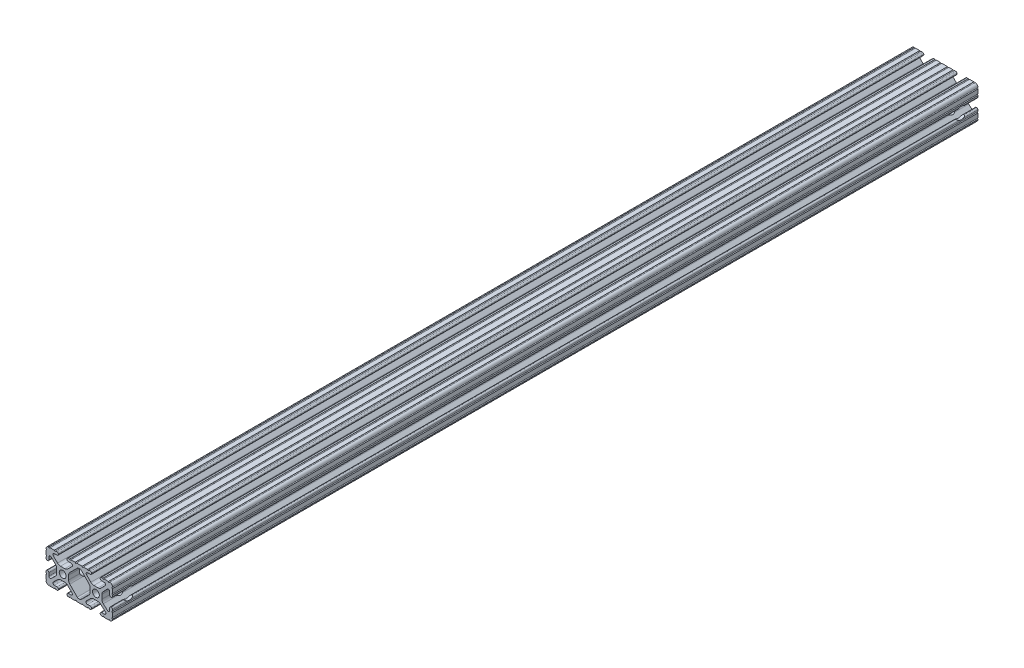
from build123d import *

# Parameters (mm, degrees)
SKETCH1_R               = 2.6035
BOSS_EXTRUDE1_DEPTH     = 330.2
SKETCH2_R               = 4.445
CUT_EXTRUDE1_DEPTH      = 9.191498123
CUT_EXTRUDE1_DEPTH_BACK = 43.608501877


with BuildPart() as part:
    # Sketch1 → Boss-Extrude1 (new body, symmetric)
    with BuildSketch(Plane.XY):
        with BuildLine():
            Line((18.01710265, 12.7), (16.98745015, 12.7))
            ThreePointArc((16.98745015, 12.7), (16.245730386, 12.392769614), (15.9385, 11.65104985))
            Line((15.9385, 11.65104985), (15.9385, 11.53922))
            ThreePointArc((15.9385, 11.53922), (16.245750844, 10.797450844), (16.98752, 10.4902))
            Line((16.98752, 10.4902), (19.116384363, 10.4902))
            ThreePointArc((19.116384363, 10.4902), (20.052502933, 9.869096983), (19.844087081, 8.765172272))
            Line((19.844087081, 8.765172272), (16.618993479, 5.455112286))
            ThreePointArc((16.618993479, 5.455112286), (15.578994274, 4.745442459), (14.344932584, 4.4958))
            Line((14.344932584, 4.4958), (11.083317835, 4.4958))
            ThreePointArc((11.083317835, 4.4958), (9.854330953, 4.743306833), (8.816955189, 5.447238587))
            Line((8.816955189, 5.447238587), (5.564154119, 8.762652677))
            ThreePointArc((5.564154119, 8.762652677), (5.352591412, 9.867473037), (6.289393385, 10.4902))
            Line((6.289393385, 10.4902), (8.41248, 10.4902))
            ThreePointArc((8.41248, 10.4902), (9.154249156, 10.797450844), (9.4615, 11.53922))
            Line((9.4615, 11.53922), (9.4615, 11.65104985))
            ThreePointArc((9.4615, 11.65104985), (9.154269614, 12.392769614), (8.41254985, 12.7))
            Line((8.41254985, 12.7), (7.38288465, 12.7))
            ThreePointArc((7.38288465, 12.7), (6.87488465, 12.192), (6.36688465, 12.7))
            Line((6.36688465, 12.7), (3.14958095, 12.7))
            ThreePointArc((3.14958095, 12.7), (2.64158095, 12.192), (2.13358095, 12.7))
            Line((2.13358095, 12.7), (-2.13358095, 12.7))
            ThreePointArc((-2.13358095, 12.7), (-2.64158095, 12.192), (-3.14958095, 12.7))
            Line((-3.14958095, 12.7), (-6.36689735, 12.7))
            ThreePointArc((-6.36689735, 12.7), (-6.87489735, 12.192), (-7.38289735, 12.7))
            Line((-7.38289735, 12.7), (-8.41254985, 12.7))
            ThreePointArc((-8.41254985, 12.7), (-9.154269614, 12.392769614), (-9.4615, 11.65104985))
            Line((-9.4615, 11.65104985), (-9.4615, 11.53922))
            ThreePointArc((-9.4615, 11.53922), (-9.154249156, 10.797450844), (-8.41248, 10.4902))
            Line((-8.41248, 10.4902), (-6.283641037, 10.4902))
            ThreePointArc((-6.283641037, 10.4902), (-5.297291557, 9.829633109), (-5.532576693, 8.666071843))
            Line((-5.532576693, 8.666071843), (-8.809985098, 5.416263103))
            ThreePointArc((-8.809985098, 5.416263103), (-9.836720513, 4.734920264), (-11.045536121, 4.4958))
            Line((-11.045536121, 4.4958), (-14.354463879, 4.4958))
            ThreePointArc((-14.354463879, 4.4958), (-15.563279487, 4.734920264), (-16.590014902, 5.416263103))
            Line((-16.590014902, 5.416263103), (-19.867423307, 8.666071843))
            ThreePointArc((-19.867423307, 8.666071843), (-20.102708443, 9.829633109), (-19.116358963, 10.4902))
            Line((-19.116358963, 10.4902), (-16.98752, 10.4902))
            ThreePointArc((-16.98752, 10.4902), (-16.245750844, 10.797450844), (-15.9385, 11.53922))
            Line((-15.9385, 11.53922), (-15.9385, 11.65104985))
            ThreePointArc((-15.9385, 11.65104985), (-16.245730386, 12.392769614), (-16.98745015, 12.7))
            Line((-16.98745015, 12.7), (-18.01711535, 12.7))
            ThreePointArc((-18.01711535, 12.7), (-18.52511535, 12.192), (-19.03311535, 12.7))
            Line((-19.03311535, 12.7), (-22.2504, 12.7))
            ThreePointArc((-22.2504, 12.7), (-22.758323491, 12.192000006), (-23.266399977, 12.699846982))
            ThreePointArc((-23.266399977, 12.699846982), (-24.782522516, 12.082522516), (-25.399846982, 10.566399977))
            ThreePointArc((-25.399846982, 10.566399977), (-24.892000006, 10.058323491), (-25.4, 9.5504))
            Line((-25.4, 9.5504), (-25.4, 6.3330836))
            ThreePointArc((-25.4, 6.3330836), (-24.892, 5.8250836), (-25.4, 5.3170836))
            Line((-25.4, 5.3170836), (-25.4, 4.237520184))
            ThreePointArc((-25.4, 4.237520184), (-25.107393763, 3.531106237), (-24.400979816, 3.2385))
            Line((-24.400979816, 3.2385), (-24.23922, 3.2385))
            ThreePointArc((-24.23922, 3.2385), (-23.497450844, 3.545750844), (-23.1902, 4.28752))
            Line((-23.1902, 4.28752), (-23.1902, 6.334741132))
            ThreePointArc((-23.1902, 6.334741132), (-22.556026952, 7.286023527), (-21.434002553, 7.066535717))
            Line((-21.434002553, 7.066535717), (-18.147950853, 3.808156468))
            ThreePointArc((-18.147950853, 3.808156468), (-17.452759693, 2.774838327), (-17.208501877, 1.553619571))
            Line((-17.208501877, 1.553619571), (-17.208501877, -1.695179196))
            ThreePointArc((-17.208501877, -1.695179196), (-17.450738657, -2.911536421), (-18.140486065, -3.942289578))
            Line((-18.140486065, -3.942289578), (-21.431579576, -7.227386226))
            ThreePointArc((-21.431579576, -7.227386226), (-22.55444896, -7.449940594), (-23.1902, -6.498002195))
            Line((-23.1902, -6.498002195), (-23.1902, -4.28752))
            ThreePointArc((-23.1902, -4.28752), (-23.497450844, -3.545750844), (-24.23922, -3.2385))
            Line((-24.23922, -3.2385), (-24.35098, -3.2385))
            ThreePointArc((-24.35098, -3.2385), (-25.092749156, -3.545750844), (-25.4, -4.28752))
            Line((-25.4, -4.28752), (-25.4, -5.3171344))
            ThreePointArc((-25.4, -5.3171344), (-24.892, -5.8251344), (-25.4, -6.3331344))
            Line((-25.4, -6.3331344), (-25.4, -9.5504))
            ThreePointArc((-25.4, -9.5504), (-24.892000006, -10.058323491), (-25.399846982, -10.566399977))
            ThreePointArc((-25.399846982, -10.566399977), (-24.782522516, -12.082522516), (-23.266399977, -12.699846982))
            ThreePointArc((-23.266399977, -12.699846982), (-22.758323491, -12.192000006), (-22.2504, -12.7))
            Line((-22.2504, -12.7), (-19.03308995, -12.7))
            ThreePointArc((-19.03308995, -12.7), (-18.52508995, -12.192), (-18.01708995, -12.7))
            Line((-18.01708995, -12.7), (-16.9874692, -12.7))
            ThreePointArc((-16.9874692, -12.7), (-16.245700044, -12.392749156), (-15.9384492, -11.65098))
            Line((-15.9384492, -11.65098), (-15.9384492, -11.53922))
            ThreePointArc((-15.9384492, -11.53922), (-16.245700044, -10.797450844), (-16.9874692, -10.4902))
            Line((-16.9874692, -10.4902), (-19.116358963, -10.4902))
            ThreePointArc((-19.116358963, -10.4902), (-20.055197748, -9.862578342), (-19.834124023, -8.755124678))
            Line((-19.834124023, -8.755124678), (-16.49660751, -5.423689618))
            ThreePointArc((-16.49660751, -5.423689618), (-15.467274017, -4.736928798), (-14.253591699, -4.4958))
            Line((-14.253591699, -4.4958), (-11.146408301, -4.4958))
            ThreePointArc((-11.146408301, -4.4958), (-9.932725983, -4.736928798), (-8.90339249, -5.423689618))
            Line((-8.90339249, -5.423689618), (-5.565875977, -8.755124678))
            ThreePointArc((-5.565875977, -8.755124678), (-5.344802252, -9.862578342), (-6.283641037, -10.4902))
            Line((-6.283641037, -10.4902), (-8.4125308, -10.4902))
            ThreePointArc((-8.4125308, -10.4902), (-9.154299956, -10.797450844), (-9.4615508, -11.53922))
            Line((-9.4615508, -11.53922), (-9.4615508, -11.65098))
            ThreePointArc((-9.4615508, -11.65098), (-9.154299956, -12.392749156), (-8.4125308, -12.7))
            Line((-8.4125308, -12.7), (-7.38287195, -12.7))
            ThreePointArc((-7.38287195, -12.7), (-6.87487195, -12.192), (-6.36687195, -12.7))
            Line((-6.36687195, -12.7), (-3.14960635, -12.7))
            ThreePointArc((-3.14960635, -12.7), (-2.64160635, -12.192), (-2.13360635, -12.7))
            Line((-2.13360635, -12.7), (2.13360635, -12.7))
            ThreePointArc((2.13360635, -12.7), (2.64159365, -12.1920127), (3.14958095, -12.7))
            Line((3.14958095, -12.7), (6.36691005, -12.7))
            ThreePointArc((6.36691005, -12.7), (6.87491005, -12.192), (7.38291005, -12.7))
            Line((7.38291005, -12.7), (8.4125308, -12.7))
            ThreePointArc((8.4125308, -12.7), (9.154299956, -12.392749156), (9.4615508, -11.65098))
            Line((9.4615508, -11.65098), (9.4615508, -11.53922))
            ThreePointArc((9.4615508, -11.53922), (9.154299956, -10.797450844), (8.4125308, -10.4902))
            Line((8.4125308, -10.4902), (6.289393385, -10.4902))
            ThreePointArc((6.289393385, -10.4902), (5.231590322, -9.783049717), (5.480677245, -8.535265862))
            Line((5.480677245, -8.535265862), (8.597933595, -5.423689618))
            ThreePointArc((8.597933595, -5.423689618), (9.627267088, -4.736928798), (10.840949406, -4.4958))
            Line((10.840949406, -4.4958), (14.102564155, -4.4958))
            ThreePointArc((14.102564155, -4.4958), (15.215927525, -4.697410182), (16.187895372, -5.276636531))
            Line((16.187895372, -5.276636531), (19.868247549, -8.482246082))
            ThreePointArc((19.868247549, -8.482246082), (20.188435806, -9.746879864), (19.116384363, -10.4902))
            Line((19.116384363, -10.4902), (16.9874692, -10.4902))
            ThreePointArc((16.9874692, -10.4902), (16.245700044, -10.797450844), (15.9384492, -11.53922))
            Line((15.9384492, -11.53922), (15.9384492, -11.65098))
            ThreePointArc((15.9384492, -11.65098), (16.245700044, -12.392749156), (16.9874692, -12.7))
            Line((16.9874692, -12.7), (18.01710265, -12.7))
            ThreePointArc((18.01710265, -12.7), (18.52510265, -12.192), (19.03310265, -12.7))
            Line((19.03310265, -12.7), (22.2504, -12.7))
            ThreePointArc((22.2504, -12.7), (22.758323491, -12.192000006), (23.266399977, -12.699846982))
            ThreePointArc((23.266399977, -12.699846982), (24.782522516, -12.082522516), (25.399846982, -10.566399977))
            ThreePointArc((25.399846982, -10.566399977), (24.892000006, -10.058323492), (25.4, -9.550400001))
            Line((25.4, -9.550400001), (25.4, -6.333083592))
            ThreePointArc((25.4, -6.333083592), (24.892000001, -5.825083593), (25.4, -5.317083593))
            Line((25.4, -5.317083593), (25.4, -4.237520184))
            ThreePointArc((25.4, -4.237520184), (25.107393763, -3.531106237), (24.400979816, -3.2385))
            Line((24.400979816, -3.2385), (24.189220184, -3.2385))
            ThreePointArc((24.189220184, -3.2385), (23.482806237, -3.531106237), (23.1902, -4.237520184))
            Line((23.1902, -4.237520184), (23.1902, -6.155876159))
            ThreePointArc((23.1902, -6.155876159), (22.62232736, -7.038258539), (21.583974541, -6.886926384))
            Line((21.583974541, -6.886926384), (18.29817066, -4.024970844))
            ThreePointArc((18.29817066, -4.024970844), (17.493730985, -2.946044689), (17.208501877, -1.630807374))
            Line((17.208501877, -1.630807374), (17.208501877, 1.630807374))
            ThreePointArc((17.208501877, 1.630807374), (17.442348332, 2.82673414), (18.109440981, 3.846495088))
            Line((18.109440981, 3.846495088), (21.526346532, 7.353420386))
            ThreePointArc((21.526346532, 7.353420386), (22.585896263, 7.574939077), (23.1902, 6.676867167))
            Line((23.1902, 6.676867167), (23.1902, 4.237520184))
            ThreePointArc((23.1902, 4.237520184), (23.482806237, 3.531106237), (24.189220184, 3.2385))
            Line((24.189220184, 3.2385), (24.400979816, 3.2385))
            ThreePointArc((24.400979816, 3.2385), (25.107393763, 3.531106237), (25.4, 4.237520184))
            Line((25.4, 4.237520184), (25.4, 5.3170836))
            ThreePointArc((25.4, 5.3170836), (24.891949193, 5.825134407), (25.4, 6.333185215))
            Line((25.4, 6.333185215), (25.4, 9.550400015))
            ThreePointArc((25.4, 9.550400015), (24.892000013, 10.058323498), (25.399846982, 10.566399977))
            ThreePointArc((25.399846982, 10.566399977), (24.782522516, 12.082522516), (23.266399977, 12.699846982))
            ThreePointArc((23.266399977, 12.699846982), (22.758323491, 12.192000006), (22.2504, 12.7))
            Line((22.2504, 12.7), (19.03310265, 12.7))
            ThreePointArc((19.03310265, 12.7), (18.52510265, 12.192), (18.01710265, 12.7))
        make_face()
        with Locations((-12.7, 0)):
            Circle(SKETCH1_R, mode=Mode.SUBTRACT)
        with Locations((12.7, 0)):
            Circle(SKETCH1_R, mode=Mode.SUBTRACT)
        with BuildLine():
            Line((-7.259513935, -3.869413038), (-1.545748891, -9.572766749))
            ThreePointArc((-1.545748891, -9.572766749), (-1.035199478, -9.913400116), (-0.433213048, -10.033))
            Line((-0.433213048, -10.033), (0.433213048, -10.033))
            ThreePointArc((0.433213048, -10.033), (1.035199478, -9.913400116), (1.545748891, -9.572766749))
            Line((1.545748891, -9.572766749), (7.259513935, -3.869413038))
            ThreePointArc((7.259513935, -3.869413038), (7.949261343, -2.838659881), (8.191498123, -1.622302656))
            Line((8.191498123, -1.622302656), (8.191498123, 1.622302656))
            ThreePointArc((8.191498123, 1.622302656), (7.955573352, 2.823327967), (7.282860769, 3.845864069))
            Line((7.282860769, 3.845864069), (1.675572808, 9.561086461))
            ThreePointArc((1.675572808, 9.561086461), (1.161034429, 9.910236611), (0.551456936, 10.033))
            Line((0.551456936, 10.033), (-0.395199982, 10.033))
            ThreePointArc((-0.395199982, 10.033), (-0.994772524, 9.914396349), (-1.50403329, 9.576450301))
            Line((-1.50403329, 9.576450301), (-7.252049147, 3.876839553))
            ThreePointArc((-7.252049147, 3.876839553), (-7.947240307, 2.843521412), (-8.191498123, 1.622302656))
            Line((-8.191498123, 1.622302656), (-8.191498123, -1.622302656))
            ThreePointArc((-8.191498123, -1.622302656), (-7.949261343, -2.838659881), (-7.259513935, -3.869413038))
        make_face(mode=Mode.SUBTRACT)
    extrude(amount=BOSS_EXTRUDE1_DEPTH, both=True)

    # Sketch2 → Cut-Extrude1 (cut, two sides)
    with BuildSketch(Plane.ZY.offset(17.208501877)) as cut_extrude1_sk:
        with Locations((-317.5, 0)):
            Circle(SKETCH2_R)
        with Locations((317.5, 0)):
            Circle(SKETCH2_R)
    extrude(amount=CUT_EXTRUDE1_DEPTH, mode=Mode.SUBTRACT)
    extrude(cut_extrude1_sk.sketch, amount=-CUT_EXTRUDE1_DEPTH_BACK, mode=Mode.SUBTRACT)


solid = part.part
